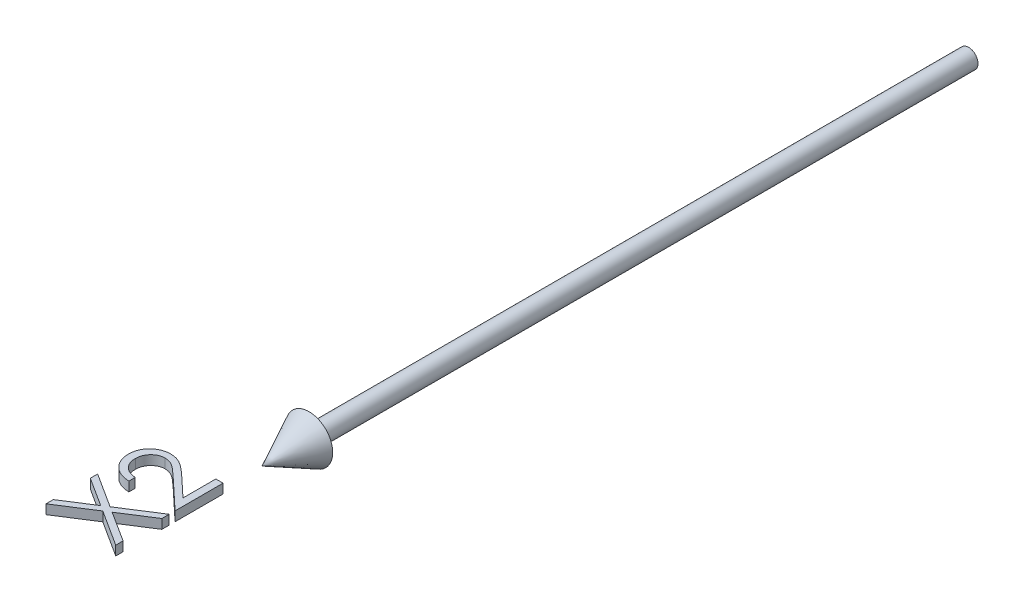
from build123d import *

# Parameters (mm, degrees)
BOSS_EXTRUDE1_DEPTH        = 1
BOSS_EXTRUDE1_DEPTH_BACK   = 1
BOSS_EXTRUDE1_2_DEPTH      = 1
BOSS_EXTRUDE1_2_DEPTH_BACK = 1


with BuildPart() as part:
    # Sketch2 → Revolve1 (revolve)
    with BuildSketch(Plane(origin=(0, 0, 0), x_dir=(1, 0, 0), z_dir=(0, 1, 0))):
        Polygon((0, -150), (5, -140), (2, -140), (2, 0), (0, 0), align=None)
    revolve(axis=Axis((0, 0, -41.949952025), (0, 0, 1)))


with BuildPart() as body_2:
    # Sketch3 → Boss-Extrude1 (new, two sides: drawn at the far end of the back side and taken through both)
    with BuildSketch(Plane(origin=(0, 0, 0), x_dir=(1, 0, 0), z_dir=(0, 1, 0)).offset(-BOSS_EXTRUDE1_DEPTH_BACK)):
        with BuildLine():
            Line((-10.384615385, -166.538461538), (-10.384615385, -167.884615385))
            add(Edge.make_bspline(
                [(-10.384615385, -167.884615385), (-10.563204904, -167.875841872), (-10.913949966, -167.858610926), (-11.425338136, -167.777918258), (-11.914144417, -167.662457355), (-12.376444048, -167.499208267), (-12.81632465, -167.296467076), (-13.232039003, -167.053338387), (-13.622001241, -166.765364742), (-13.982596283, -166.438764454), (-14.313400158, -166.084041715), (-14.599065485, -165.701301974), (-14.840426933, -165.299109), (-15.042203684, -164.878683005), (-15.193660166, -164.435280589), (-15.306038622, -163.972925484), (-15.373651532, -163.489586328), (-15.380919185, -163.160271948), (-15.384615385, -162.992788462)],
                knots=[0, 0, 0, 0, 1.10065271, 2.161652631, 3.183658789, 4.190468796, 5.17591951, 6.163126047, 7.15150782, 8.156236427, 9.156009102, 10.134482811, 11.092018607, 12.041330605, 13.001268258, 13.972401359, 14.968799086, 16, 16, 16, 16], degree=3))
            add(Edge.make_bspline(
                [(-15.384615385, -162.992788462), (-15.380796104, -162.828299426), (-15.373291355, -162.505084348), (-15.307873473, -162.033553745), (-15.207626401, -161.583600463), (-15.059076032, -161.160323818), (-14.872677813, -160.759379802), (-14.640867206, -160.385732767), (-14.37461271, -160.030347538), (-14.060552476, -159.710665804), (-13.725449413, -159.416999565), (-13.367562158, -159.163877022), (-12.997495718, -158.945885897), (-12.612359334, -158.76746697), (-12.210898815, -158.632217489), (-11.7969631, -158.532010585), (-11.365775091, -158.474726904), (-11.073881456, -158.465983611), (-10.925480769, -158.461538462)],
                knots=[0, 0, 0, 0, 1.111674182, 2.184400057, 3.212814286, 4.223731311, 5.211378316, 6.196328225, 7.191884489, 8.207283132, 9.220262353, 10.201199469, 11.166417575, 12.120932471, 13.06540007, 14.026332106, 14.996573967, 16, 16, 16, 16], degree=3))
            add(Edge.make_bspline(
                [(-10.925480769, -158.461538462), (-10.716561568, -158.468795416), (-10.302389402, -158.483181977), (-9.693752958, -158.606241919), (-9.104071894, -158.798447615), (-8.629467281, -159.02984435), (-8.247074226, -159.263343584), (-7.93207523, -159.47354984), (-7.592995253, -159.721030517), (-7.228461871, -160.003671248), (-6.843248958, -160.326339507), (-6.429497135, -160.680652418), (-5.994856958, -161.075760232), (-5.697798463, -161.352825797), (-5.543870192, -161.496394231)],
                knots=[0, 0, 0, 0, 1.184416499, 2.348048165, 3.509039915, 4.696071444, 5.333504901, 6.05069495, 6.844171097, 7.714965912, 8.667477798, 9.695072654, 10.805644396, 12, 12, 12, 12], degree=3))
            Line((-5.543870192, -161.496394231), (-1.538461538, -165.249399038))
            Line((-1.538461538, -165.249399038), (-1.538461538, -158.269230769))
            Line((-1.538461538, -158.269230769), (0, -158.269230769))
            Line((0, -158.269230769), (0, -168.461538462))
            Line((0, -168.461538462), (-6.207932692, -162.644230769))
            add(Edge.make_bspline(
                [(-6.207932692, -162.644230769), (-6.355782578, -162.502596969), (-6.639771949, -162.230547424), (-7.054384635, -161.845764952), (-7.439025524, -161.500169288), (-7.792967874, -161.191523319), (-8.121388879, -160.926522581), (-8.413651895, -160.691355873), (-8.682599539, -160.502931912), (-8.994345027, -160.298437359), (-9.374969243, -160.100377438), (-9.840113626, -159.930181627), (-10.318944709, -159.826403705), (-10.642524868, -159.81395441), (-10.805288462, -159.807692308)],
                knots=[0, 0, 0, 0, 1.329631726, 2.553950428, 3.673215718, 4.687767853, 5.603093632, 6.413772471, 7.123043292, 7.734684054, 8.834405432, 9.900288307, 10.943827018, 12, 12, 12, 12], degree=3))
            add(Edge.make_bspline(
                [(-10.805288462, -159.807692308), (-10.907637312, -159.810416918), (-11.109347242, -159.8157866), (-11.405086209, -159.863176732), (-11.690363983, -159.934793187), (-11.966058065, -160.037415722), (-12.229396573, -160.172873179), (-12.48070006, -160.337759093), (-12.723652768, -160.528002222), (-12.951452617, -160.748079091), (-13.160086355, -160.989842747), (-13.344903864, -161.245246674), (-13.499357196, -161.515461406), (-13.625972184, -161.799347644), (-13.725295246, -162.096113942), (-13.794117729, -162.406334278), (-13.837328375, -162.72915149), (-13.843174826, -162.949580758), (-13.846153846, -163.061899038)],
                knots=[0, 0, 0, 0, 0.991446411, 1.95395049, 2.89581595, 3.838931463, 4.798493298, 5.75982156, 6.748411868, 7.785213223, 8.824556874, 9.840280684, 10.836137867, 11.835679398, 12.848801643, 13.863922112, 14.911575587, 16, 16, 16, 16], degree=3))
            add(Edge.make_bspline(
                [(-13.846153846, -163.061899038), (-13.843210339, -163.17923205), (-13.837429778, -163.409654711), (-13.793644926, -163.747248098), (-13.727267069, -164.07152127), (-13.621844545, -164.377635783), (-13.497282594, -164.672220352), (-13.339040059, -164.948986061), (-13.155158717, -165.21252807), (-12.941940801, -165.458511623), (-12.702375061, -165.683172895), (-12.438357077, -165.883342841), (-12.151787569, -166.057090331), (-11.843842673, -166.208895124), (-11.511456406, -166.332119496), (-11.155884194, -166.426294196), (-10.778648675, -166.500808117), (-10.518141312, -166.525701936), (-10.384615385, -166.538461538)],
                knots=[0, 0, 0, 0, 1.030878251, 2.024474673, 2.987898669, 3.934362936, 4.864849709, 5.795128259, 6.730474222, 7.685293701, 8.650606017, 9.611896181, 10.591709709, 11.591680886, 12.625074257, 13.701333388, 14.821793024, 16, 16, 16, 16], degree=3))
        make_face()
    extrude(amount=BOSS_EXTRUDE1_DEPTH + BOSS_EXTRUDE1_DEPTH_BACK)


with BuildPart() as body_3:
    # Sketch3 → Boss-Extrude1 2 (new, two sides: drawn at the far end of the back side and taken through both)
    with BuildSketch(Plane(origin=(0, 0, 0), x_dir=(1, 0, 0), z_dir=(0, 1, 0)).offset(-BOSS_EXTRUDE1_2_DEPTH_BACK)):
        Polygon((-15, -180.865384615), (-15, -179.311899038), (-8.864182692, -175.384615385), (-15, -171.457331731), (-15, -169.903846154), (-7.650240385, -174.606370192), (0, -169.711538462), (0, -171.265024038), (-6.436298077, -175.384615385), (0, -179.504206731), (0, -181.057692308), (-7.650240385, -176.159855769), align=None)
    extrude(amount=BOSS_EXTRUDE1_2_DEPTH + BOSS_EXTRUDE1_2_DEPTH_BACK)


solid = Compound([part.part, body_2.part, body_3.part])
